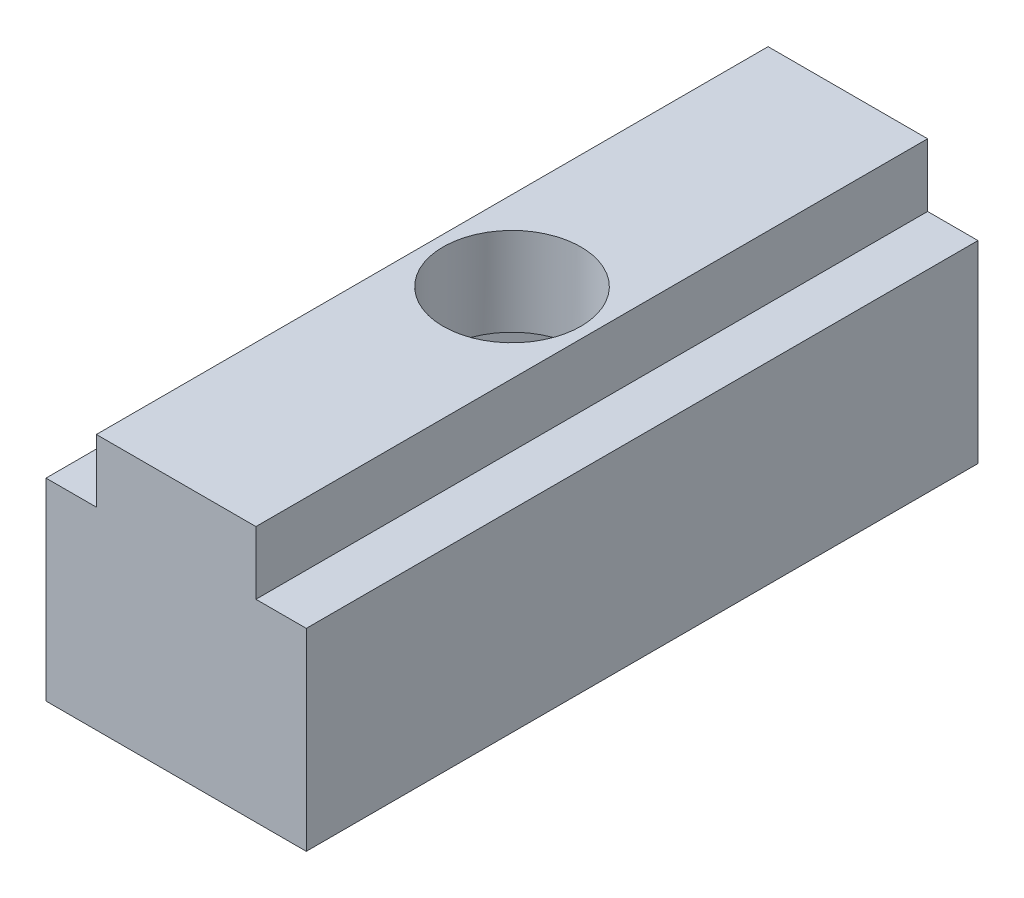
from build123d import *

# Parameters (mm, degrees)
BOSS_EXTRUDE1_DEPTH = 40
CUT_EXTRUDE1_REACH  = 17.25
SKETCH2_R           = 4.1
CUT_EXTRUDE2_DEPTH  = 10


with BuildPart() as part:
    # Sketch1 → Boss-Extrude1 (new body)
    with BuildSketch(Plane(origin=(0, 0, 0), x_dir=(0, 1, 0), z_dir=(0, 0, 1))):
        Polygon((0, 0), (0, 15.5), (11.5, 15.5), (11.5, 12.5), (15.25, 12.5), (15.25, 3), (11.5, 3), (11.5, 0), align=None)
    extrude(amount=BOSS_EXTRUDE1_DEPTH)

    # Sketch2 → Cut-Extrude1 (cut, up to next)
    with BuildSketch(Plane(origin=(0, 15.25, 0), x_dir=(-1, 0, 0), z_dir=(0, 1, 0)), mode=Mode.PRIVATE) as cut_extrude1_sk1:
        with Locations((7.75, 20)):
            Circle(SKETCH2_R)
    cut_extrude1_tool1 = extrude(cut_extrude1_sk1.sketch, amount=-CUT_EXTRUDE1_REACH, mode=Mode.PRIVATE) & part.part
    add(cut_extrude1_tool1.solids().sort_by_distance((-7.75, 15.25, 20))[0], mode=Mode.SUBTRACT)

    # Sketch3 → Cut-Extrude2 (cut)
    with BuildSketch(Plane(origin=(0, 0, 0), x_dir=(-1, 0, 0), z_dir=(0, -1, 0))):
        Polygon((2.440808402, -14.694736773), (0.500911472, -21.945263183), (5.81010307, -27.250526411), (13.059191598, -25.305263227), (14.999088528, -18.054736817), (9.68989693, -12.749473589), align=None)
    extrude(amount=-CUT_EXTRUDE2_DEPTH, mode=Mode.SUBTRACT)


solid = part.part
